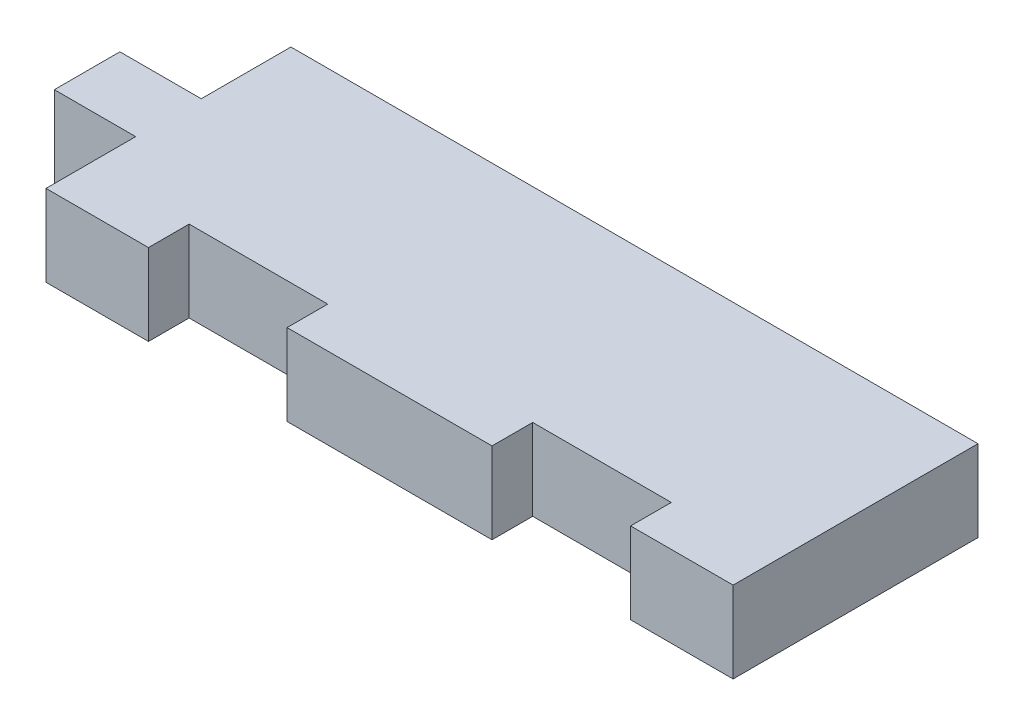
from build123d import *

# Parameters (mm, degrees)
BOSS_EXTRUDE1_DEPTH = 6.35


with BuildPart() as part:
    # Sketch1 → Boss-Extrude1 (new body)
    with BuildSketch(Plane(origin=(0, 0, 0), x_dir=(1, 0, 0), z_dir=(0, 1, 0))):
        Polygon((-33.17059633, 2.56), (-26.82059633, 2.56), (-26.82059633, 9.56), (26.82059633, 9.56), (26.82059633, -9.56), (18.82059633, -9.56), (18.82059633, -6.385), (8, -6.385), (8, -9.56), (-8, -9.56), (-8, -6.385), (-18.82059633, -6.385), (-18.82059633, -9.56), (-26.82059633, -9.56), (-26.82059633, -2.56), (-33.17059633, -2.56), align=None)
    extrude(amount=BOSS_EXTRUDE1_DEPTH)


solid = part.part
